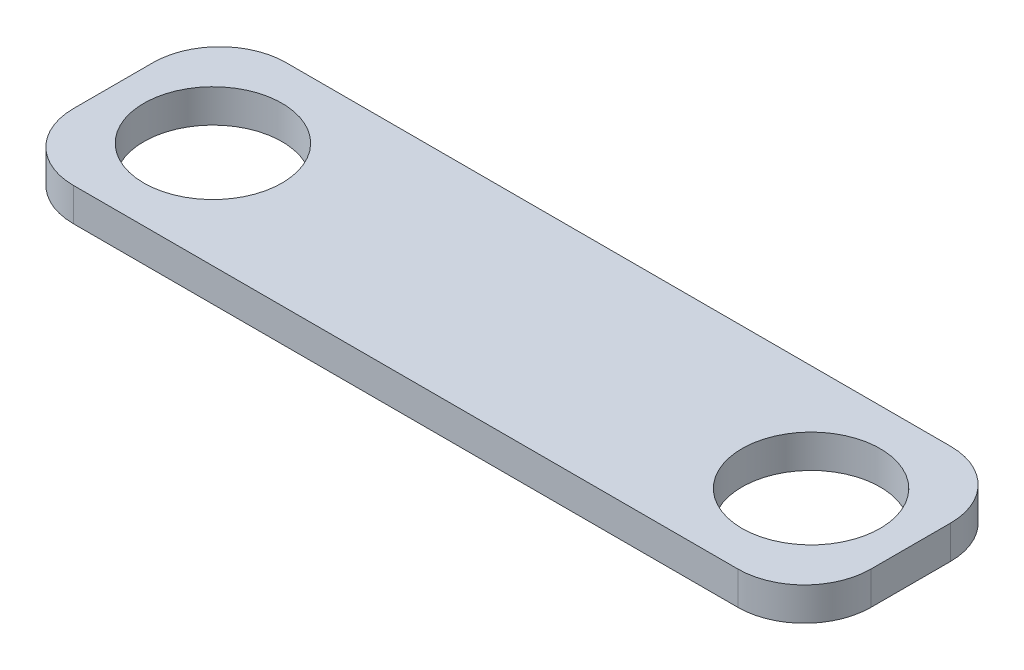
from build123d import *

# Parameters (mm, degrees)
SKETCH1_R           = 5.2
BOSS_EXTRUDE1_DEPTH = 2.5


with BuildPart() as part:
    # Sketch1 → Boss-Extrude1 (new body)
    with BuildSketch(Plane(origin=(0, 0, 0), x_dir=(1, 0, 0), z_dir=(0, 1, 0))):
        with BuildLine():
            Line((25, -8), (-25, -8))
            ThreePointArc((-25, -8), (-28.535533906, -6.535533906), (-30, -3))
            Line((-30, -3), (-30, 3))
            ThreePointArc((-30, 3), (-28.535533906, 6.535533906), (-25, 8))
            Line((-25, 8), (25, 8))
            ThreePointArc((25, 8), (28.535533906, 6.535533906), (30, 3))
            Line((30, 3), (30, -3))
            ThreePointArc((30, -3), (28.535533906, -6.535533906), (25, -8))
        make_face()
        with Locations((-22.5, 0)):
            Circle(SKETCH1_R, mode=Mode.SUBTRACT)
        with Locations((22.5, 0)):
            Circle(SKETCH1_R, mode=Mode.SUBTRACT)
    extrude(amount=BOSS_EXTRUDE1_DEPTH)


solid = part.part
